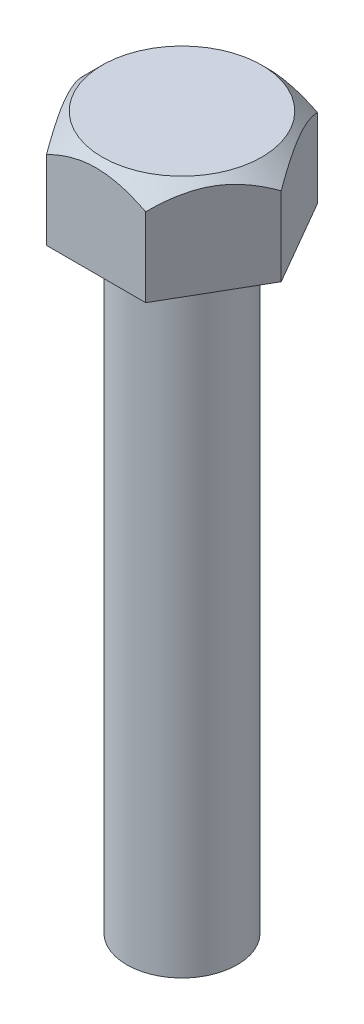
from build123d import *

# Parameters (mm, degrees)
SKETCH1_R           = 2.25
BOSS_EXTRUDE1_DEPTH = 25
BOSS_EXTRUDE2_DEPTH = 4
SKETCH3_OUTSIDE_W   = 24.264
SKETCH3_OUTSIDE_H   = 23.182
SKETCH3_OUTSIDE_R   = 3.25
CUT_EXTRUDE1_DEPTH  = 4
CUT_EXTRUDE1_TAPER  = 45


with BuildPart() as part:
    # Sketch1 → Boss-Extrude1 (new body)
    with BuildSketch(Plane(origin=(0, 0, 0), x_dir=(1, 0, 0), z_dir=(0, 1, 0))):
        Circle(SKETCH1_R)
    extrude(amount=BOSS_EXTRUDE1_DEPTH)

    # Sketch2 → Boss-Extrude2 (add)
    with BuildSketch(Plane(origin=(0, 25, 0), x_dir=(1, 0, 0), z_dir=(0, 1, 0))):
        Polygon((4.041451884, 0), (2.020725942, 3.5), (-2.020725942, 3.5), (-4.041451884, 0), (-2.020725942, -3.5), (2.020725942, -3.5), align=None)
    extrude(amount=BOSS_EXTRUDE2_DEPTH)

    # Sketch3 outside → Cut-Extrude1 (cut)
    with BuildSketch(Plane(origin=(0, 29, 0), x_dir=(1, 0, 0), z_dir=(0, 1, 0))):
        Rectangle(SKETCH3_OUTSIDE_W, SKETCH3_OUTSIDE_H)
        Circle(SKETCH3_OUTSIDE_R, mode=Mode.SUBTRACT)
    extrude(amount=-CUT_EXTRUDE1_DEPTH, taper=CUT_EXTRUDE1_TAPER, mode=Mode.SUBTRACT)


solid = part.part
